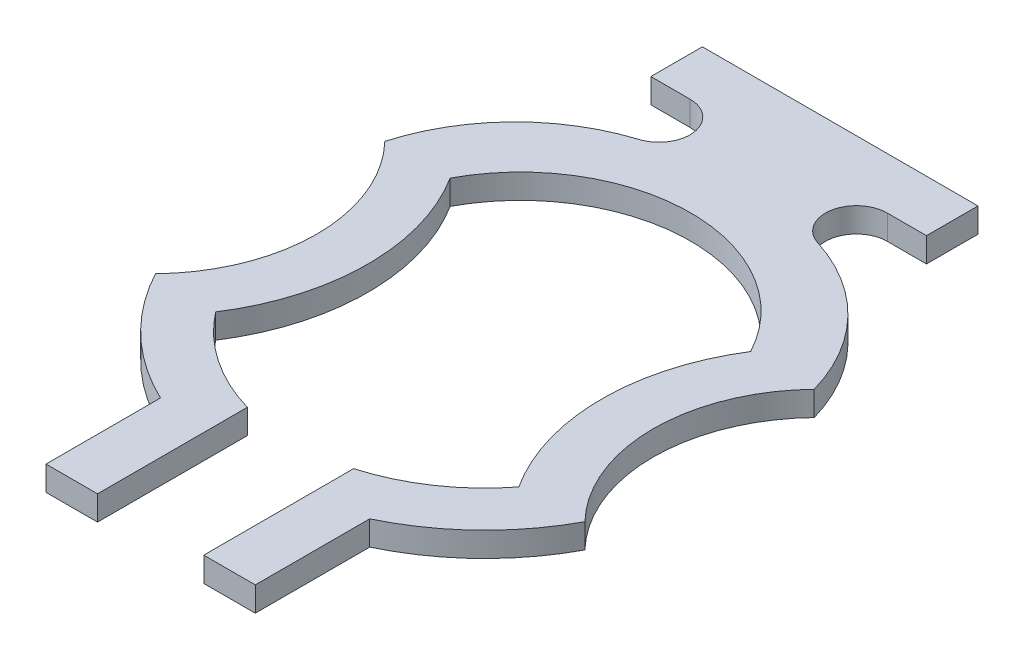
from build123d import *

# Parameters (mm, degrees)
BOSS_EXTRUDE1_DEPTH = 0.1


with BuildPart() as part:
    # Sketch1 → Boss-Extrude1 (new body)
    with BuildSketch(Plane(origin=(0, 0, 0), x_dir=(1, 0, 0), z_dir=(0, 1, 0))):
        with BuildLine():
            Line((-0.5617, 1.4483), (0.5617, 1.4483))
            Line((0.5617, 1.4483), (0.5617, 1.2383))
            Line((0.5617, 1.2383), (0.402164983, 1.2383))
            ThreePointArc((0.402164983, 1.2383), (0.277526345, 1.131342099), (0.364324457, 0.991911577))
            ThreePointArc((0.364324457, 0.991911577), (0.68584629, 0.794012708), (0.875117893, 0.467337775))
            ThreePointArc((0.875117893, 0.467337775), (0.6862, -7.013e-06), (0.87512764, -0.467347861))
            ThreePointArc((0.87512764, -0.467347861), (0.685156757, -0.717511413), (0.4265, -0.895745589))
            Line((0.4265, -0.895745589), (0.4265, -1.3623))
            Line((0.4265, -1.3623), (0.2165, -1.3623))
            Line((0.2165, -1.3623), (0.2165, -0.751537198))
            ThreePointArc((0.2165, -0.751537198), (0.438784382, -0.647416926), (0.617847888, -0.479525179))
            ThreePointArc((0.617847888, -0.479525179), (0.476214849, -0.00511934), (0.612334438, 0.470897757))
            ThreePointArc((0.612334438, 0.470897757), (0, 0.8385), (-0.612334438, 0.470897757))
            ThreePointArc((-0.612334438, 0.470897757), (-0.476214849, -0.00511934), (-0.617847888, -0.479525179))
            ThreePointArc((-0.617847888, -0.479525179), (-0.438784382, -0.647416926), (-0.2165, -0.751537198))
            Line((-0.2165, -0.751537198), (-0.2165, -1.3623))
            Line((-0.2165, -1.3623), (-0.4265, -1.3623))
            Line((-0.4265, -1.3623), (-0.4265, -0.895745589))
            ThreePointArc((-0.4265, -0.895745589), (-0.685156757, -0.717511413), (-0.87512764, -0.467347861))
            ThreePointArc((-0.87512764, -0.467347861), (-0.6862, -7.013e-06), (-0.875117893, 0.467337775))
            ThreePointArc((-0.875117893, 0.467337775), (-0.68584629, 0.794012708), (-0.364324457, 0.991911577))
            ThreePointArc((-0.364324457, 0.991911577), (-0.277526345, 1.131342099), (-0.402164983, 1.2383))
            Line((-0.402164983, 1.2383), (-0.5617, 1.2383))
            Line((-0.5617, 1.2383), (-0.5617, 1.4483))
        make_face()
    extrude(amount=BOSS_EXTRUDE1_DEPTH)


solid = part.part
